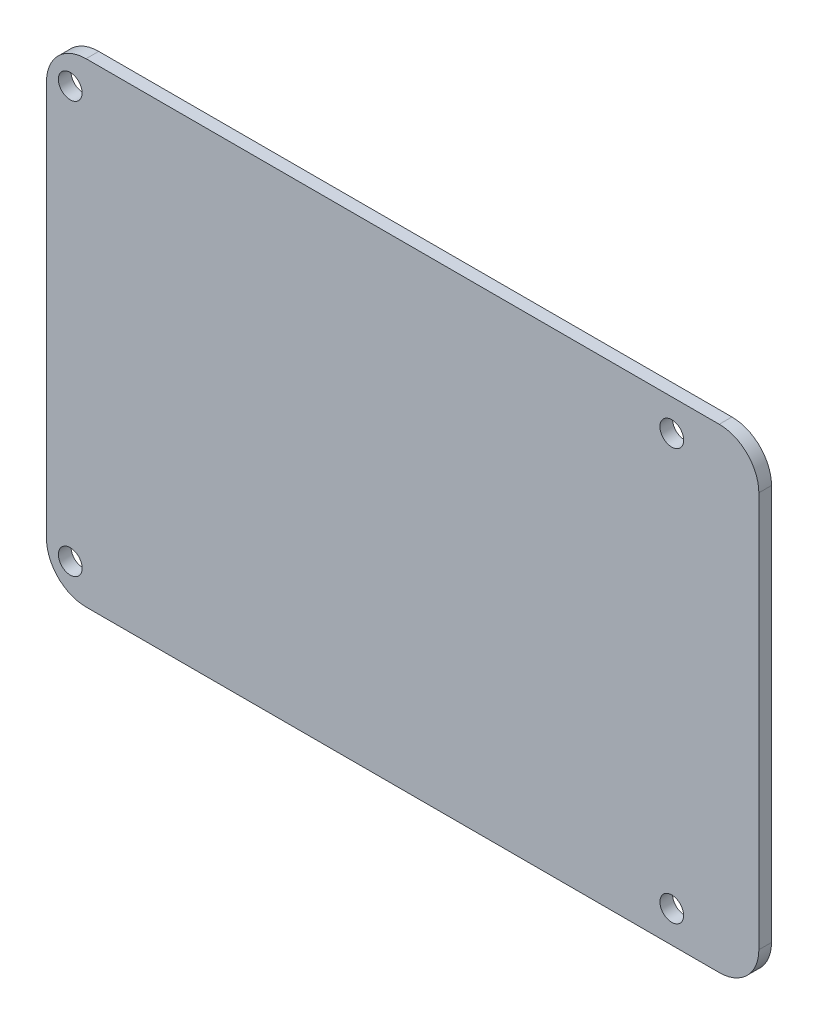
from build123d import *

# Parameters (mm, degrees)
SKETCH1_W           = 90
SKETCH1_H           = 60
BOSS_EXTRUDE1_DEPTH = 1.6
FILLET1_R           = 5
SKETCH2_R           = 1.5
CUT_EXTRUDE1_DEPTH  = 1.6


with BuildPart() as part:
    # Sketch1 → Boss-Extrude1 (new body)
    with BuildSketch(Plane.XY):
        with Locations((45, 30)):
            Rectangle(SKETCH1_W, SKETCH1_H)
    extrude(amount=BOSS_EXTRUDE1_DEPTH)

    # Fillet1
    fillet1_edges = [part.edges().sort_by_distance(p)[0] for p in [
        (0, 60, 0.8),
        (90, 60, 0.8),
        (90, 0, 0.8),
        (0, 0, 0.8),
    ]]
    fillet(fillet1_edges, radius=FILLET1_R)

    # Sketch2 → Cut-Extrude1 (cut)
    with BuildSketch(Plane.XY.offset(1.6)):
        with Locations((79, 56)):
            Circle(SKETCH2_R)
        with Locations((3, 56)):
            Circle(SKETCH2_R)
    cut_extrude1 = extrude(amount=-CUT_EXTRUDE1_DEPTH, mode=Mode.SUBTRACT)

    # Mirror1: Cut-Extrude1 across plane
    add(cut_extrude1.mirror(Plane(origin=(0, 30, 0), x_dir=(0, 0, 1), z_dir=(0, -1, 0))), mode=Mode.SUBTRACT)


solid = part.part
